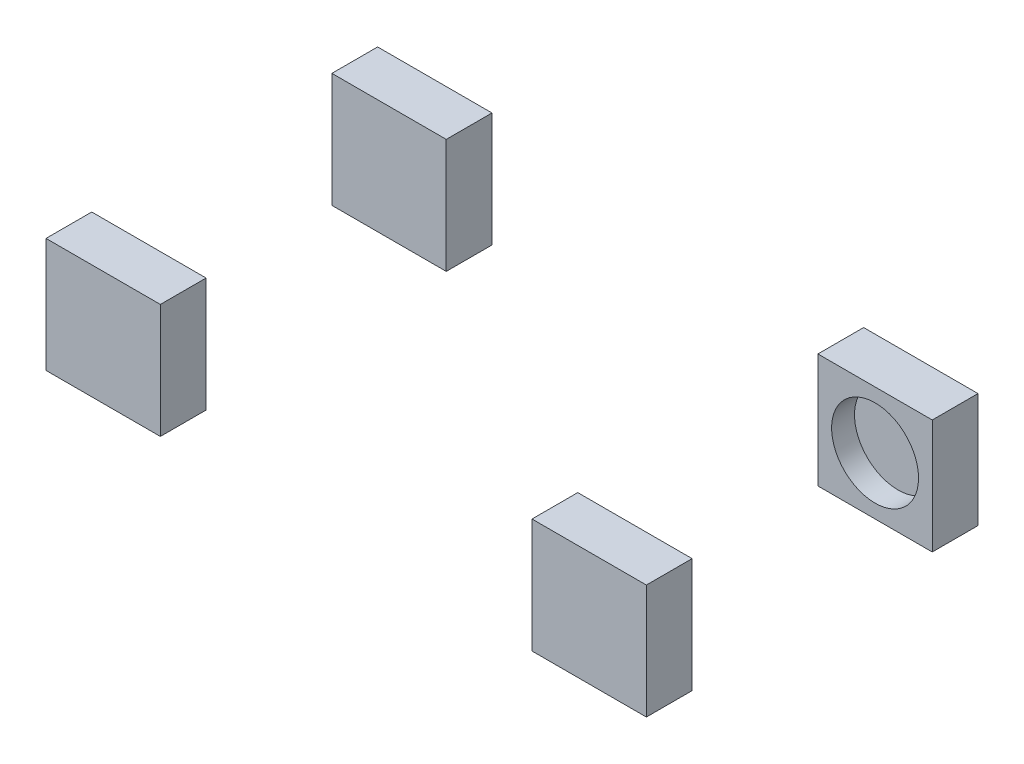
from build123d import *

# Parameters (mm, degrees)
SKETCH1_W             = 100
SKETCH1_H             = 40
BOSS_EXTRUDE1_DEPTH   = 50
BOSS_EXTRUDE1_2_DEPTH = 50
BOSS_EXTRUDE1_3_DEPTH = 50
BOSS_EXTRUDE1_4_DEPTH = 50
SKETCH3_R             = 38
CUT_EXTRUDE5_DEPTH    = 20
SKETCH4_R             = 38
CUT_EXTRUDE6_DEPTH    = 20


with BuildPart() as part:
    # Sketch1 → Boss-Extrude1 (new body, symmetric)
    with BuildSketch(Plane(origin=(0, 0, 0), x_dir=(1, 0, 0), z_dir=(0, 1, 0))):
        with Locations((212.5, 125)):
            Rectangle(SKETCH1_W, SKETCH1_H)
    extrude(amount=BOSS_EXTRUDE1_DEPTH, both=True)

    # Sketch4 → Cut-Extrude6 (cut)
    with BuildSketch(Plane.XY.offset(-105)):
        with Locations((212.5, 0)):
            Circle(SKETCH4_R)
    extrude(amount=-CUT_EXTRUDE6_DEPTH, mode=Mode.SUBTRACT)


with BuildPart() as body_2:
    # Sketch1 → Boss-Extrude1 2 (new body, symmetric)
    with BuildSketch(Plane(origin=(0, 0, 0), x_dir=(1, 0, 0), z_dir=(0, 1, 0))):
        with Locations((212.5, -125)):
            Rectangle(SKETCH1_W, SKETCH1_H)
    extrude(amount=BOSS_EXTRUDE1_2_DEPTH, both=True)

    # Sketch3 → Cut-Extrude5 (cut)
    with BuildSketch(Plane(origin=(0, 0, 105), x_dir=(-1, 0, 0), z_dir=(0, 0, -1))):
        with Locations((-212.5, 0)):
            Circle(SKETCH3_R)
    extrude(amount=-CUT_EXTRUDE5_DEPTH, mode=Mode.SUBTRACT)


with BuildPart() as body_3:
    # Sketch1 → Boss-Extrude1 3 (new body, symmetric)
    with BuildSketch(Plane(origin=(0, 0, 0), x_dir=(1, 0, 0), z_dir=(0, 1, 0))):
        with Locations((-212.5, -125)):
            Rectangle(SKETCH1_W, SKETCH1_H)
    extrude(amount=BOSS_EXTRUDE1_3_DEPTH, both=True)


with BuildPart() as body_4:
    # Sketch1 → Boss-Extrude1 4 (new body, symmetric)
    with BuildSketch(Plane(origin=(0, 0, 0), x_dir=(1, 0, 0), z_dir=(0, 1, 0))):
        with Locations((-212.5, 125)):
            Rectangle(SKETCH1_W, SKETCH1_H)
    extrude(amount=BOSS_EXTRUDE1_4_DEPTH, both=True)


solid = Compound([part.part, body_2.part, body_3.part, body_4.part])
